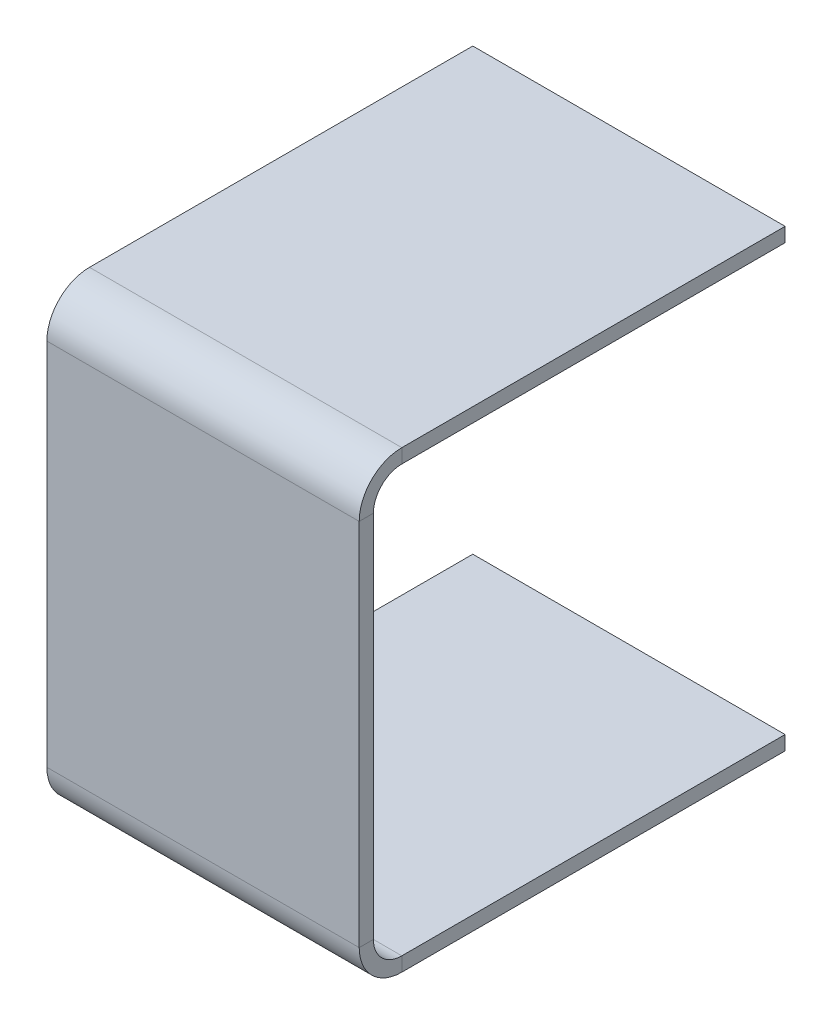
from build123d import *

# Parameters (mm, degrees)
SKETCH1_W = 22
SKETCH1_H = 1


with BuildPart() as part:
    # Sweep1: sweep along a path in Sketch2
    with BuildLine(Plane(origin=(0, 0, 0), x_dir=(0, 0, -1), z_dir=(1, 0, 0))) as sweep1_path:
        Line((0, 15.5), (-27, 15.5))
        ThreePointArc((-27, 15.5), (-28.767766953, 14.767766953), (-29.5, 13))
        Line((-29.5, 13), (-29.5, -13))
        ThreePointArc((-29.5, -13), (-28.767766953, -14.767766953), (-27, -15.5))
        Line((-27, -15.5), (0, -15.5))
    # Sketch1 → Sweep1 (sweep)
    with BuildSketch(Plane.XY):
        with Locations((0, 15.5)):
            Rectangle(SKETCH1_W, SKETCH1_H)
    sweep(path=sweep1_path.line)


solid = part.part
